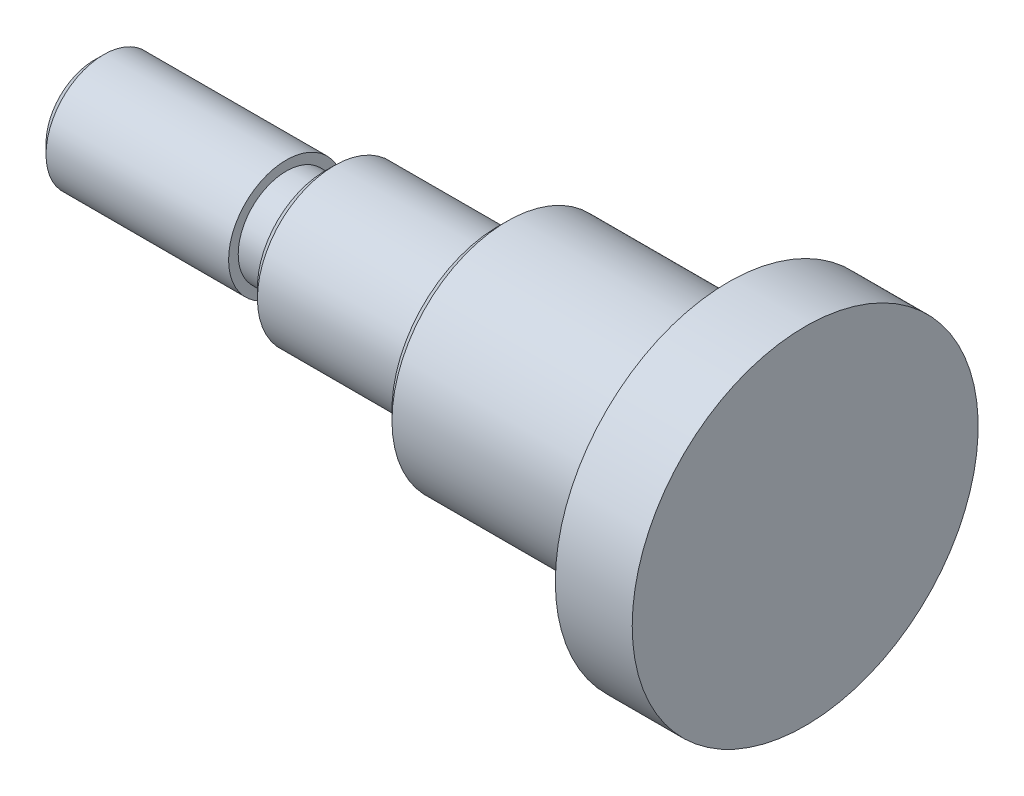
from build123d import *

# Parameters (mm, degrees)
CHANFREIN1_SIZE = 0.5
CHANFREIN2_SIZE = 0.5
CHANFREIN3_SIZE = 0.5


with BuildPart() as part:
    # Esquisse1 → Révolution1 (revolve)
    with BuildSketch(Plane.XY, mode=Mode.PRIVATE) as r_volution1_sk:
        Polygon((0, 0), (0, 9), (-4, 9), (-4, 6), (-16, 6), (-16, 4), (-25, 4), (-25, 3), (-25, 2.5), (-27, 2.5), (-27, 3), (-37, 3), (-37, 0), align=None)
    revolve(r_volution1_sk.sketch.rotate(Axis((-37, 0, 0), (1, 0, 0)), 90), axis=Axis((-37, 0, 0), (1, 0, 0)))  # turned: the seam where the file's is

    # Chanfrein1
    chanfrein1_edges = [part.edges().sort_by_distance(p)[0] for p in [
        (-37, 0, -3),
    ]]
    chamfer(chanfrein1_edges, length=CHANFREIN1_SIZE)

    # Chanfrein2
    chanfrein2_edges = [part.edges().sort_by_distance(p)[0] for p in [
        (-16, 0, -6),
    ]]
    chamfer(chanfrein2_edges, length=CHANFREIN2_SIZE)

    # Chanfrein3
    chanfrein3_edges = [part.edges().sort_by_distance(p)[0] for p in [
        (-25, 0, -4),
    ]]
    chamfer(chanfrein3_edges, length=CHANFREIN3_SIZE)


solid = part.part
